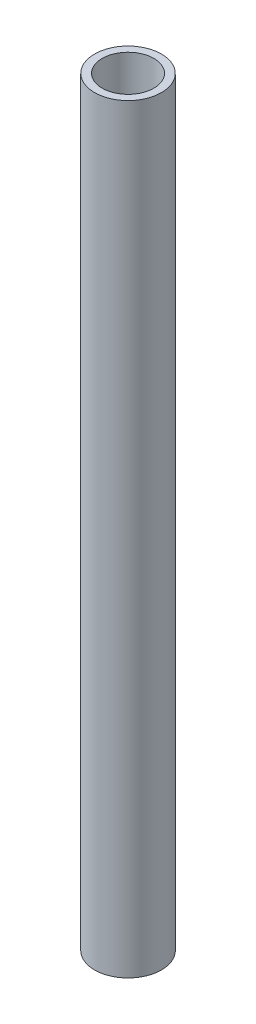
from build123d import *

# Parameters (mm, degrees)
SKETCH_1_R      = 13.2
SKETCH_1_R_2    = 10.2
EXTRUDE_1_DEPTH = 300


with BuildPart() as part:
    # Эскиз1 → Вытянуть-Тонкостенный1 (new body)
    with BuildSketch(Plane(origin=(0, 0, 0), x_dir=(1, 0, 0), z_dir=(0, 1, 0))):
        Circle(SKETCH_1_R)
        Circle(SKETCH_1_R_2, mode=Mode.SUBTRACT)
    extrude(amount=EXTRUDE_1_DEPTH)


solid = part.part
